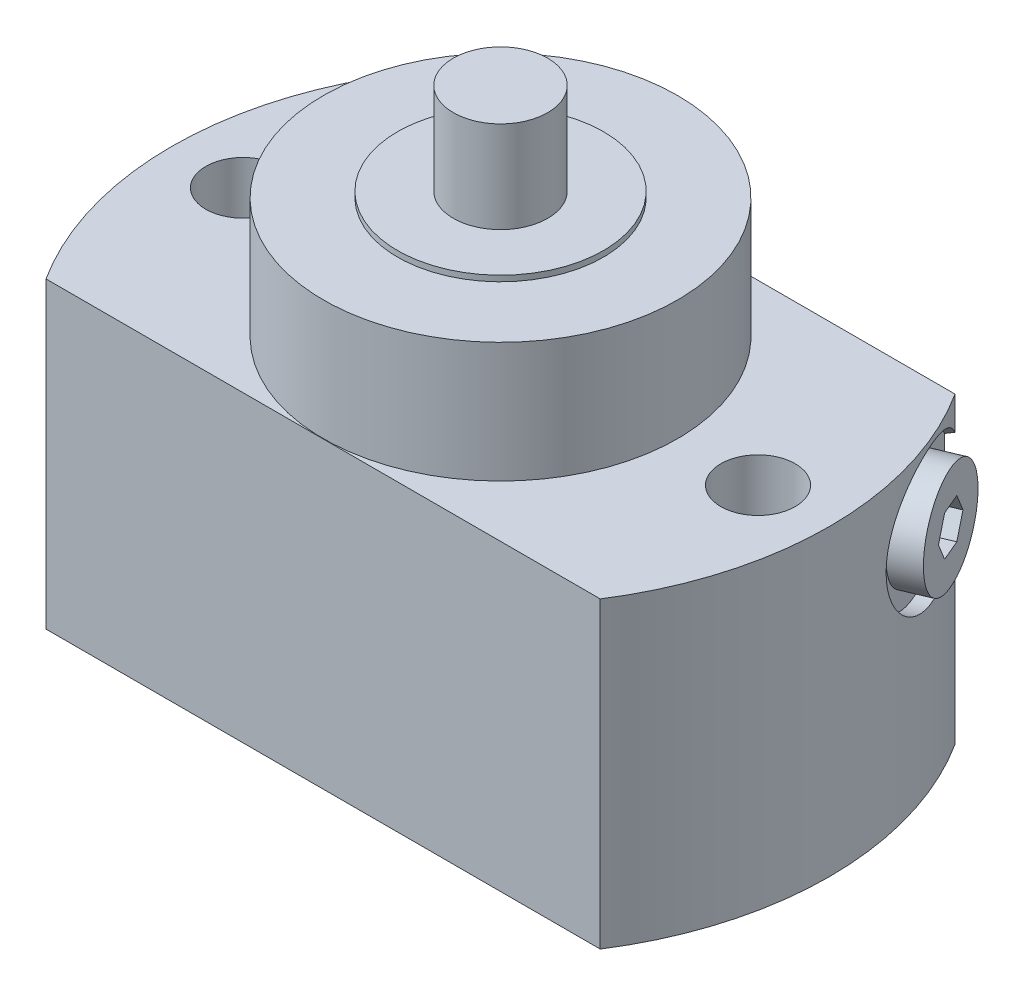
from build123d import *

# Parameters (mm, degrees)
EXTRUDE1_DEPTH     = 53
HOLE1_D            = 13
HOLE1_DEPTH        = 53
SKETCH5_R          = 4
CUT_EXTRUDE1_DEPTH = 4
SKETCH6_R          = 5.5
CUT_EXTRUDE2_DEPTH = 3
SKETCH7_R          = 2
CUT_EXTRUDE3_DEPTH = 33
CUT_EXTRUDE4_DEPTH = 5


with BuildPart() as part:
    # Sketch1 → Extrude1 (new body)
    with BuildSketch(Plane(origin=(0, 0, 0), x_dir=(1, 0, 0), z_dir=(0, 1, 0))):
        with BuildLine():
            Line((-48.427781283, 31), (48.427781283, 31))
            ThreePointArc((48.427781283, 31), (57.5, 0), (48.427781283, -31))
            Line((48.427781283, -31), (-48.427781283, -31))
            ThreePointArc((-48.427781283, -31), (-57.5, 0), (-48.427781283, 31))
        make_face()
    extrude(amount=EXTRUDE1_DEPTH)

    # Sketch2 → Revolve1 (revolve)
    with BuildSketch(Plane.XY, mode=Mode.PRIVATE) as revolve1_sk:
        Polygon((0, 91), (-8.25, 91), (-8.25, 75), (-18, 75), (-18, 74), (-30.95, 74), (-30.95, 53), (0, 53), align=None)
    revolve(revolve1_sk.sketch.rotate(Axis((0, 0, 0), (0, 1, 0)), 270), axis=Axis((0, 0, 0), (0, 1, 0)))  # turned: the seam where the file's is

    # Hole1
    with Locations(Plane(origin=(0, 53, 0), x_dir=(-1, 0, 0), z_dir=(0, 1, 0))):
        with Locations((45, 0), (-45, 0)):
            Hole(HOLE1_D / 2, depth=HOLE1_DEPTH)

    # Sketch5 → Cut-Extrude1 (cut)
    with BuildSketch(Plane.XZ):
        with Locations(Location((0, 0, 0), (0, 0, 270))):  # turned: the seam where the file's is
            Circle(SKETCH5_R)
    extrude(amount=-CUT_EXTRUDE1_DEPTH, mode=Mode.SUBTRACT)

    # Sketch6 → Cut-Extrude2 (cut)
    with BuildSketch(Plane.XZ):
        with Locations(Location((35, -15, 0), (0, 0, 270))):  # turned: the seam where the file's is
            Circle(SKETCH6_R)
    extrude(amount=-CUT_EXTRUDE2_DEPTH, mode=Mode.SUBTRACT)

    # Sketch7 → Cut-Extrude3 (cut)
    with BuildSketch(Plane.XZ.offset(-3)):
        with Locations(Location((35, -15, 0), (0, 0, 270))):  # turned: the seam where the file's is
            Circle(SKETCH7_R)
    extrude(amount=-CUT_EXTRUDE3_DEPTH, mode=Mode.SUBTRACT)

    # Sketch8 → Cut-Revolve1 (revolve, cut)
    with BuildSketch(Plane(origin=(0, 0, 0), x_dir=(0.920504853, 0, -0.390731128), z_dir=(0.390731128, 0, 0.920504853)), mode=Mode.PRIVATE) as cut_revolve1_sk:
        Polygon((57.5, 28), (55, 28), (55, 33.4215), (53.517364509, 34.2775), (35, 34.2775), (35, 40), (57.5, 40), align=None)
    revolve(cut_revolve1_sk.sketch.rotate(Axis((47.484793311, 40, -20.156098913), (-0.920504853, 0, 0.390731128)), 270), axis=Axis((47.484793311, 40, -20.156098913), (-0.920504853, 0, 0.390731128)), mode=Mode.SUBTRACT)  # turned: the seam where the file's is

    # Sketch9 → Revolve2 (revolve)
    with BuildSketch(Plane(origin=(0, 0, 0), x_dir=(0.920504853, 0, -0.390731128), z_dir=(0.390731128, 0, 0.920504853)), mode=Mode.PRIVATE) as revolve2_sk:
        Polygon((55, 31), (55, 34.2775), (46, 34.2775), (45, 35.2775), (45, 40), (60, 40), (60, 31), align=None)
    revolve(revolve2_sk.sketch.rotate(Axis((68.658528533, 40, -29.14381628), (-0.920504853, 0, 0.390731128)), 270), axis=Axis((68.658528533, 40, -29.14381628), (-0.920504853, 0, 0.390731128)))  # turned: the seam where the file's is

    # Sketch10 → Cut-Extrude4 (cut)
    with BuildSketch(Plane(origin=(55.230291207, 0, -23.443867709), x_dir=(-0.390731128, 0, -0.920504853), z_dir=(0.920504853, 0, -0.390731128))):
        Polygon((4.041451884, 40), (2.020725942, 43.5), (-2.020725942, 43.5), (-4.041451884, 40), (-2.020725942, 36.5), (2.020725942, 36.5), align=None)
    extrude(amount=-CUT_EXTRUDE4_DEPTH, mode=Mode.SUBTRACT)


solid = part.part
